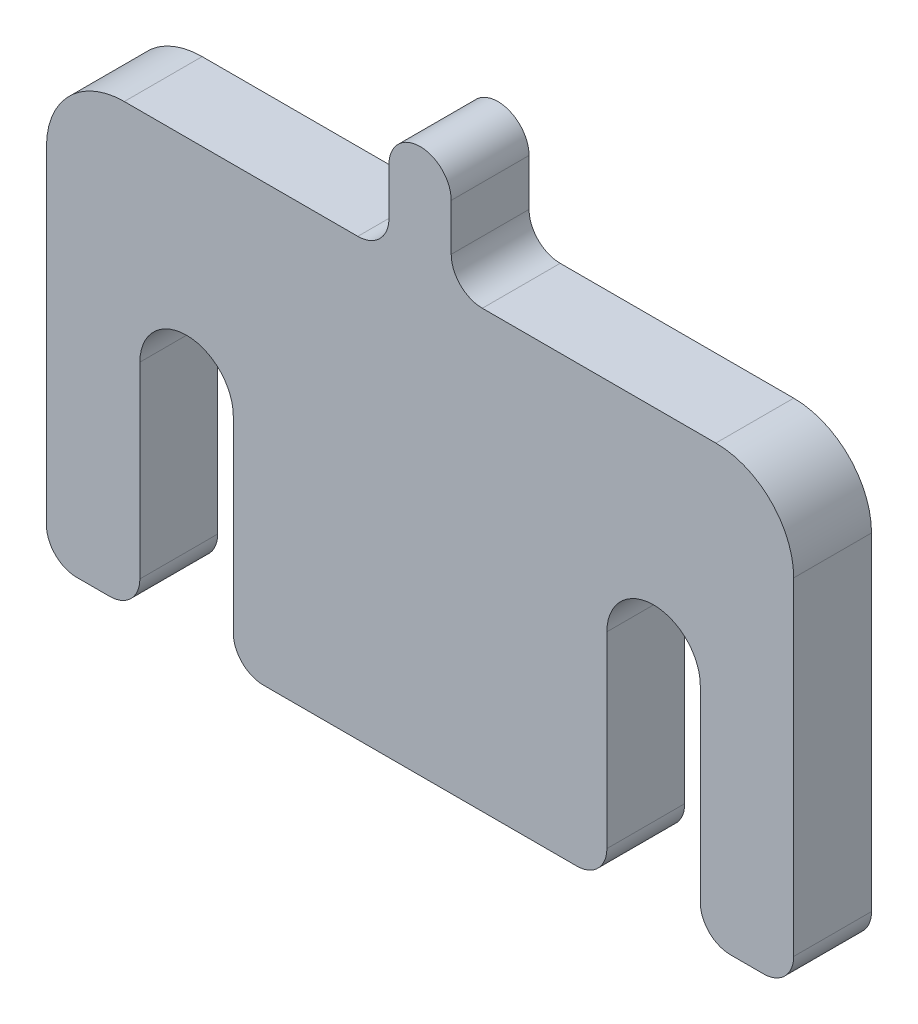
from build123d import *

# Parameters (mm, degrees)
DODANIE_WYCI_GNI_CIE1_DEPTH = 5


with BuildPart() as part:
    # Szkic1 → Dodanie-wyciągnięcie1 (new body)
    with BuildSketch(Plane.XY):
        with BuildLine():
            Line((18, 0), (18, -12.05974013))
            ThreePointArc((18, -12.05974013), (18.568288959, -13.431711041), (19.94025987, -14))
            Line((19.94025987, -14), (22.05974013, -14))
            ThreePointArc((22.05974013, -14), (23.431711041, -13.431711041), (24, -12.05974013))
            Line((24, -12.05974013), (24, 9))
            ThreePointArc((24, 9), (22.535533906, 12.535533906), (19, 14))
            Line((19, 14), (4, 14))
            ThreePointArc((4, 14), (2.585786438, 14.585786438), (2, 16))
            Line((2, 16), (2, 19))
            ThreePointArc((2, 19), (0, 21), (-2, 19))
            Line((-2, 19), (-2, 16))
            ThreePointArc((-2, 16), (-2.585786438, 14.585786438), (-4, 14))
            Line((-4, 14), (-19, 14))
            ThreePointArc((-19, 14), (-22.535533906, 12.535533906), (-24, 9))
            Line((-24, 9), (-24, -12.05974013))
            ThreePointArc((-24, -12.05974013), (-23.431711041, -13.431711041), (-22.05974013, -14))
            Line((-22.05974013, -14), (-19.94025987, -14))
            ThreePointArc((-19.94025987, -14), (-18.568288959, -13.431711041), (-18, -12.05974013))
            Line((-18, -12.05974013), (-18, 0))
            ThreePointArc((-18, 0), (-15, 3), (-12, 0))
            Line((-12, 0), (-12, -12.05974013))
            ThreePointArc((-12, -12.05974013), (-11.431711041, -13.431711041), (-10.05974013, -14))
            Line((-10.05974013, -14), (10.05974013, -14))
            ThreePointArc((10.05974013, -14), (11.431711041, -13.431711041), (12, -12.05974013))
            Line((12, -12.05974013), (12, 0))
            ThreePointArc((12, 0), (15, 3), (18, 0))
        make_face()
    extrude(amount=DODANIE_WYCI_GNI_CIE1_DEPTH)


solid = part.part
